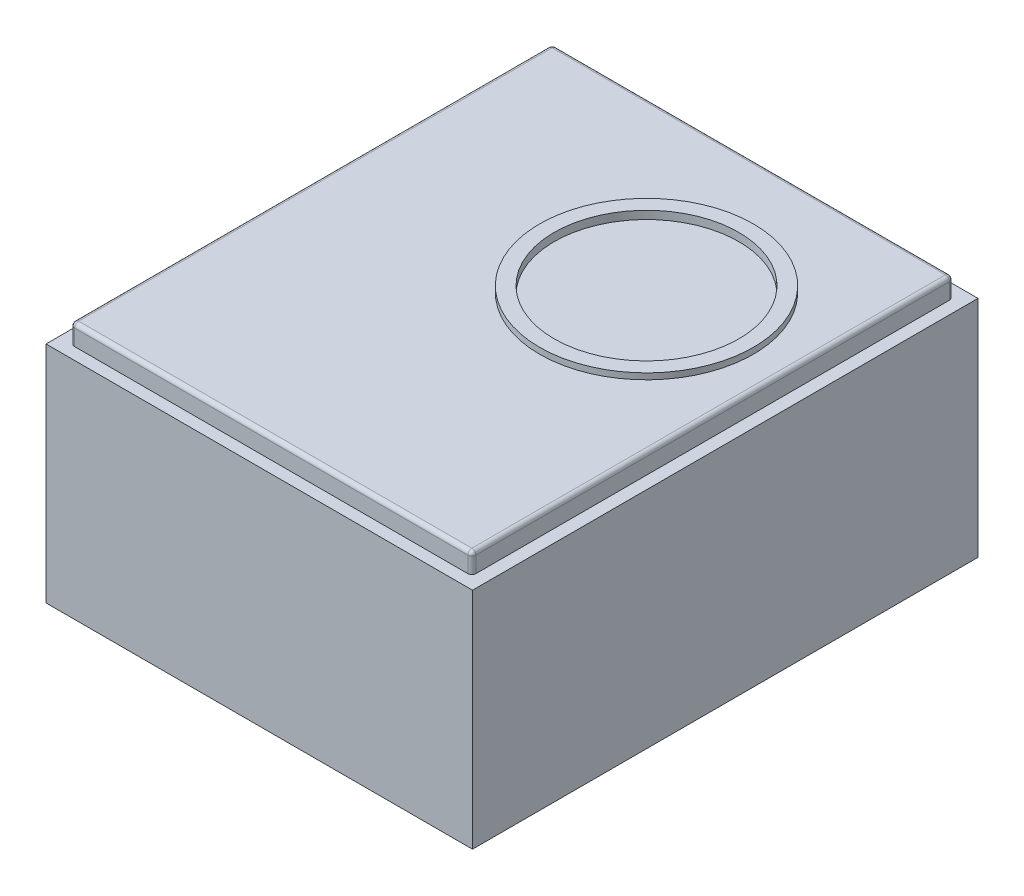
from build123d import *

# Parameters (mm, degrees)
SKETCH1_W           = 270
SKETCH1_H           = 320
BOSS_EXTRUDE1_DEPTH = 142
SKETCH3_W           = 254
SKETCH3_H           = 304.8
BOSS_EXTRUDE3_DEPTH = 12.7
FILLET1_R           = 2.54
FILLET2_R           = 2.54
SKETCH7_R           = 67.678561976
BOSS_EXTRUDE4_DEPTH = 3.81
SKETCH8_R           = 58.425044715
CUT_EXTRUDE2_DEPTH  = 5.08


with BuildPart() as part:
    # Sketch1 → Boss-Extrude1 (new body)
    with BuildSketch(Plane(origin=(0, 0, 0), x_dir=(1, 0, 0), z_dir=(0, 1, 0))):
        Rectangle(SKETCH1_W, SKETCH1_H)
    extrude(amount=BOSS_EXTRUDE1_DEPTH)

    # Sketch3 → Boss-Extrude3 (add)
    with BuildSketch(Plane(origin=(0, 142, 0), x_dir=(1, 0, 0), z_dir=(0, 1, 0))):
        Rectangle(SKETCH3_W, SKETCH3_H)
    extrude(amount=BOSS_EXTRUDE3_DEPTH)

    # Fillet1
    fillet1_edges = [part.edges().sort_by_distance(p)[0] for p in [
        (127, 148.35, 152.4),
        (127, 148.35, -152.4),
        (-127, 148.35, -152.4),
        (-127, 148.35, 152.4),
    ]]
    fillet(fillet1_edges, radius=FILLET1_R)

    # Fillet2
    fillet2_edges = [part.edges().sort_by_distance(p)[0] for p in [
        (0, 154.7, -152.4),
        (127, 154.7, 0),
        (-127, 154.7, 0),
        (0, 154.7, 152.4),
        (126.256051224, 154.7, 151.656051224),
        (-126.256051224, 154.7, 151.656051224),
        (-126.256051224, 154.7, -151.656051224),
        (126.256051224, 154.7, -151.656051224),
    ]]
    fillet(fillet2_edges, radius=FILLET2_R)

    # Sketch7 → Boss-Extrude4 (add)
    with BuildSketch(Plane(origin=(0, 154.7, 0), x_dir=(1, 0, 0), z_dir=(0, 1, 0))):
        with Locations((39.597638404, 45.550655758)):
            Circle(SKETCH7_R)
    extrude(amount=BOSS_EXTRUDE4_DEPTH)

    # Sketch8 → Cut-Extrude2 (cut)
    with BuildSketch(Plane(origin=(0, 158.51, 0), x_dir=(1, 0, 0), z_dir=(0, 1, 0))):
        with Locations((39.597638404, 45.550655758)):
            Circle(SKETCH8_R)
    extrude(amount=-CUT_EXTRUDE2_DEPTH, mode=Mode.SUBTRACT)


solid = part.part
